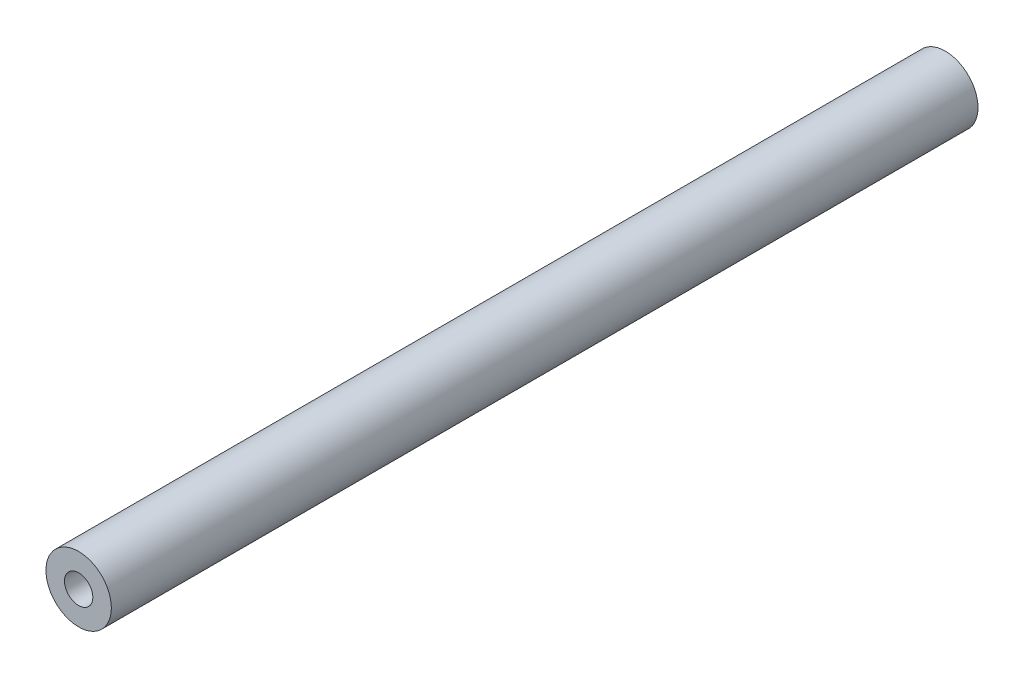
from build123d import *

# Parameters (mm, degrees)
SKETCH1_R                        = 6
BOSS_EXTRUDE1_DEPTH              = 100
BOSS_EXTRUDE1_DEPTH_BACK         = 59
TAP_DRILL_FOR_M5_HELICOIL1_D     = 5.2
TAP_DRILL_FOR_M5_HELICOIL1_DEPTH = 30
TAP_DRILL_FOR_M5_HELICOIL1_TIP   = 1.562237609
TAP_DRILL_FOR_M5_HELICOIL2_D     = 5.2
TAP_DRILL_FOR_M5_HELICOIL2_DEPTH = 30
TAP_DRILL_FOR_M5_HELICOIL2_TIP   = 1.562237609


with BuildPart() as part:
    # Sketch1 → Boss-Extrude1 (new body, two sides)
    with BuildSketch(Plane.XY) as boss_extrude1_sk:
        Circle(SKETCH1_R)
    extrude(amount=BOSS_EXTRUDE1_DEPTH)
    extrude(boss_extrude1_sk.sketch, amount=-BOSS_EXTRUDE1_DEPTH_BACK)

    # Tap Drill for M5 Helicoil1
    with Locations(Plane.XY.offset(100)):
        with Locations((0, 0)):
            Hole(TAP_DRILL_FOR_M5_HELICOIL1_D / 2, depth=TAP_DRILL_FOR_M5_HELICOIL1_DEPTH)
            with Locations((0, 0, -(TAP_DRILL_FOR_M5_HELICOIL1_DEPTH + TAP_DRILL_FOR_M5_HELICOIL1_TIP / 2))):  # 118° drill point
                Cone(0, TAP_DRILL_FOR_M5_HELICOIL1_D / 2, TAP_DRILL_FOR_M5_HELICOIL1_TIP, mode=Mode.SUBTRACT)

    # Tap Drill for M5 Helicoil2
    with Locations(Plane(origin=(0, 0, -59), x_dir=(-1, 0, 0), z_dir=(0, 0, -1))):
        with Locations((0, 0)):
            Hole(TAP_DRILL_FOR_M5_HELICOIL2_D / 2, depth=TAP_DRILL_FOR_M5_HELICOIL2_DEPTH)
            with Locations((0, 0, -(TAP_DRILL_FOR_M5_HELICOIL2_DEPTH + TAP_DRILL_FOR_M5_HELICOIL2_TIP / 2))):  # 118° drill point
                Cone(0, TAP_DRILL_FOR_M5_HELICOIL2_D / 2, TAP_DRILL_FOR_M5_HELICOIL2_TIP, mode=Mode.SUBTRACT)


solid = part.part
